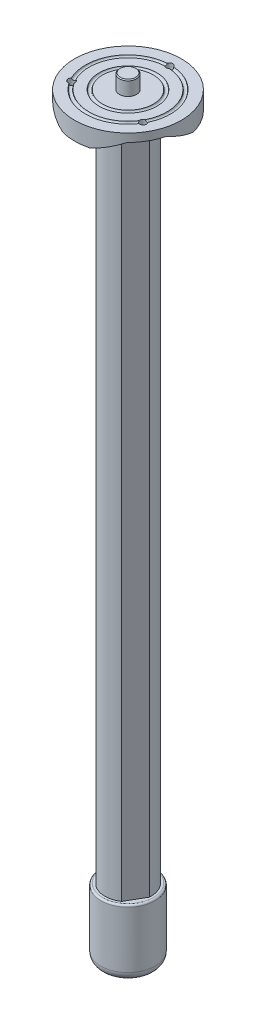
from build123d import *

# Parameters (mm, degrees)
EXTRUDE1_DEPTH                  = 185
SKETCH3_R                       = 29.5
EXTRUDE2_DEPTH                  = 10
SKETCH7_R                       = 1
SKETCH6_OUTSIDE_W               = 138.81
SKETCH6_OUTSIDE_H               = 138.81
SKETCH6_OUTSIDE_R               = 29.5
SKETCH6_OUTSIDE_R_2             = 25.5
EXTRUDE4_DEPTH                  = 5.5
EXTRUDE3_DEPTH                  = 23
CIRPATTERN1_COUNT               = 3
SKETCH8_R                       = 4.7625
EXTRUDE5_DEPTH                  = 8
CHAMFER1_SIZE                   = 0.5
EXTRUDE6_DEPTH                  = 8
FILLET1_R                       = 5
FILLET2_R                       = 1
SKETCH13_W                      = 1.89865
SKETCH13_H                      = 420
F_10_24_TAPPED_HOLE1_AT_2_COUNT = 2
F_10_24_TAPPED_HOLE1_AT_2_PITCH = 39.594681461
F_10_24_TAPPED_HOLE1_AT_3_COUNT = 2
F_10_24_TAPPED_HOLE1_AT_3_PITCH = 39.594681461


with BuildPart() as part:
    # Sketch2 → Extrude1 (new body, symmetric)
    with BuildSketch(Plane(origin=(0, 0, 0), x_dir=(1, 0, 0), z_dir=(0, 1, 0))):
        with BuildLine():
            Line((-5.6, 11.45436598), (5.6, 11.45436598))
            ThreePointArc((5.6, 11.45436598), (11.041823898, 6.375), (12.719771923, -0.877440729))
            Line((12.719771923, -0.877440729), (7.119771923, -10.576925251))
            ThreePointArc((7.119771923, -10.576925251), (0, -12.75), (-7.119771923, -10.576925251))
            Line((-7.119771923, -10.576925251), (-12.719771923, -0.877440729))
            ThreePointArc((-12.719771923, -0.877440729), (-11.041823898, 6.375), (-5.6, 11.45436598))
        make_face()
    extrude(amount=EXTRUDE1_DEPTH, both=True)


with BuildPart() as body_2:
    # Sketch3 → Extrude2 (new body)
    with BuildSketch(Plane(origin=(0, 185, 0), x_dir=(1, 0, 0), z_dir=(0, 1, 0))):
        Circle(SKETCH3_R)
    extrude(amount=EXTRUDE2_DEPTH)

    # Sketch7 → Cut-Revolve1 (revolve, cut)
    with BuildSketch(Plane.XY):
        with Locations((15, 195)):
            Circle(SKETCH7_R)
        with Locations((22.5, 195)):
            Circle(SKETCH7_R)
    revolve(axis=Axis((0, 203.822792645, 0), (0, -1, 0)), mode=Mode.SUBTRACT)

    # Sketch6 outside → Extrude4 (cut)
    with BuildSketch(Plane.XZ.offset(-185)):
        Rectangle(SKETCH6_OUTSIDE_W, SKETCH6_OUTSIDE_H)
        Circle(SKETCH6_OUTSIDE_R, mode=Mode.SUBTRACT)
        Circle(SKETCH6_OUTSIDE_R_2)
    extrude(amount=-EXTRUDE4_DEPTH, mode=Mode.SUBTRACT)

    # Sketch4 → Extrude3 (cut)
    with BuildSketch(Plane.XY.offset(-35)):
        Polygon((8, 190.5), (-8, 190.5), (-21, 185), (21, 185), align=None)
    extrude3 = extrude(amount=EXTRUDE3_DEPTH, mode=Mode.SUBTRACT)

    # CirPattern1: Extrude3 ×3 about axis
    cirpattern1_axis = Axis((0, 0, 0), (0, 1, 0))
    for i in range(1, CIRPATTERN1_COUNT):
        add(extrude3.rotate(cirpattern1_axis, i * 360 / CIRPATTERN1_COUNT), mode=Mode.SUBTRACT)

    # Sketch13 → #10-24 Tapped Hole1 (revolve, cut)
    with BuildSketch(Plane(origin=(0, 195, -22.86), x_dir=(0, 0, 1), z_dir=(1, 0, 0))):
        with Locations((0.949325, 210)):
            Rectangle(SKETCH13_W, SKETCH13_H)
    f_10_24_tapped_hole1 = revolve(axis=Axis((0, 201.35, -22.86), (0, -1, 0)), mode=Mode.SUBTRACT)

    # #10-24 Tapped Hole1 at 2: #10-24 Tapped Hole1 ×2
    with Locations(*[Vector(0.5, 0, 0.866025404) * (i * F_10_24_TAPPED_HOLE1_AT_2_PITCH) for i in range(1, F_10_24_TAPPED_HOLE1_AT_2_COUNT)]):
        add(f_10_24_tapped_hole1, mode=Mode.SUBTRACT)

    # #10-24 Tapped Hole1 at 3: #10-24 Tapped Hole1 ×2
    with Locations(*[Vector(-0.5, 0, 0.866025404) * (i * F_10_24_TAPPED_HOLE1_AT_3_PITCH) for i in range(1, F_10_24_TAPPED_HOLE1_AT_3_COUNT)]):
        add(f_10_24_tapped_hole1, mode=Mode.SUBTRACT)


with BuildPart() as body_3:
    # Sketch8 → Extrude5 (new body)
    with BuildSketch(Plane(origin=(0, 195, 0), x_dir=(1, 0, 0), z_dir=(0, 1, 0))):
        Circle(SKETCH8_R)
    extrude(amount=EXTRUDE5_DEPTH)

    # Chamfer1
    chamfer1_edges = [body_3.edges().sort_by_distance(p)[0] for p in [
        (-4.7625, 203, 0),
    ]]
    chamfer(chamfer1_edges, length=CHAMFER1_SIZE)


with BuildPart() as body_4:
    # Sketch9 → Extrude6 (new body)
    with BuildSketch(Plane(origin=(0, 185, 0), x_dir=(1, 0, 0), z_dir=(0, 1, 0))):
        with BuildLine():
            Line((-12.719771923, -0.877440729), (-7.119771923, -10.576925251))
            ThreePointArc((-7.119771923, -10.576925251), (0, -12.75), (7.119771923, -10.576925251))
            Line((7.119771923, -10.576925251), (12.719771923, -0.877440729))
            ThreePointArc((12.719771923, -0.877440729), (11.041823898, 6.375), (5.6, 11.45436598))
            Line((5.6, 11.45436598), (-5.6, 11.45436598))
            ThreePointArc((-5.6, 11.45436598), (-11.041823898, 6.375), (-12.719771923, -0.877440729))
        make_face()
    extrude(amount=EXTRUDE6_DEPTH)

    # Combine1: union part
    add(part.part)


with BuildPart() as body_5:
    # Sketch10 → Revolve1 (revolve)
    with BuildSketch(Plane.XY):
        with BuildLine():
            Line((15, -185), (15, -220))
            ThreePointArc((15, -220), (7.90569415, -223.717082451), (0, -225))
            Line((0, -225), (0, -185))
            Line((0, -185), (15, -185))
        make_face()
    revolve(axis=Axis((0, -185, 0), (0, -1, 0)))

    # Fillet1
    fillet1_edges = [body_5.edges().sort_by_distance(p)[0] for p in [
        (-15, -220, 0),
    ]]
    fillet(fillet1_edges, radius=FILLET1_R)

    # Fillet2
    fillet2_edges = [body_5.edges().sort_by_distance(p)[0] for p in [
        (-15, -185, 0),
    ]]
    fillet(fillet2_edges, radius=FILLET2_R)


solid = Compound([body_2.part, body_3.part, body_4.part, body_5.part])
